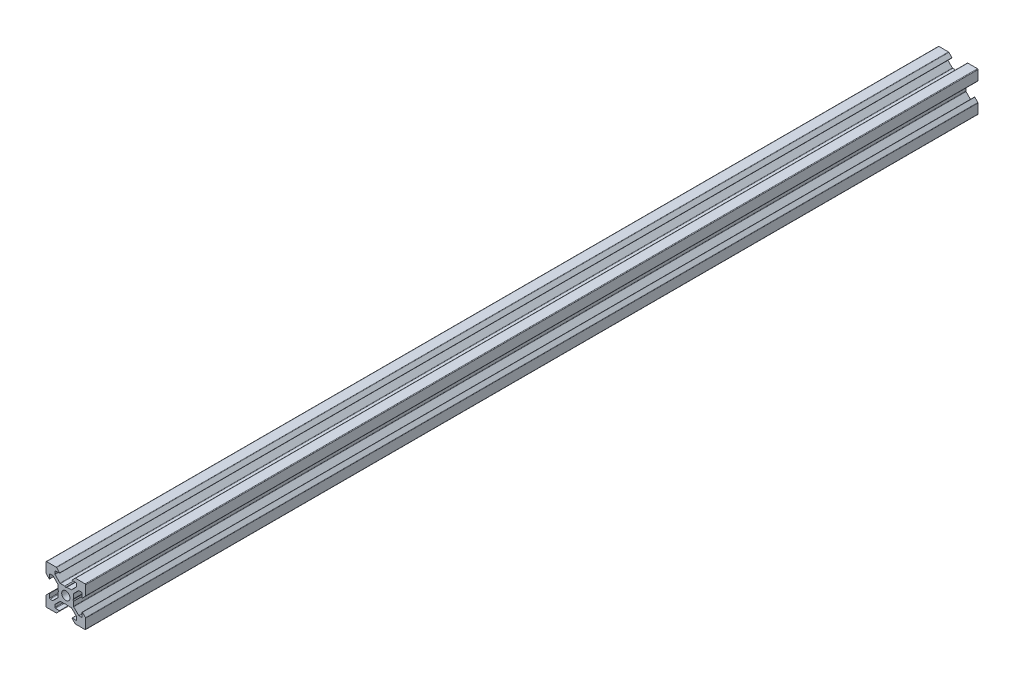
from build123d import *

# Parameters (mm, degrees)
BOSS_EXTRU_1_DEPTH = 450


with BuildPart() as part:
    # Esquisse1 → Boss.-Extru.1 (new body)
    with BuildSketch(Plane.XY):
        with BuildLine():
            Line((18.774857412, -2.895228684), (18.774857412, -4.894568513))
            ThreePointArc((18.774857412, -4.894568513), (18.686989447, -5.106700547), (18.474857412, -5.194568513))
            Line((18.474857412, -5.194568513), (17.259121481, -5.194568513))
            ThreePointArc((17.259121481, -5.194568513), (17.144316451, -5.171732372), (17.046989447, -5.106700547))
            Line((17.046989447, -5.106700547), (14.56338555, -2.62309665))
            ThreePointArc((14.56338555, -2.62309665), (14.498353724, -2.525769645), (14.475517584, -2.410964616))
            Line((14.475517584, -2.410964616), (14.475517584, -0.214843927))
            Line((14.475517584, -0.214843927), (14.175517584, 0.304771316))
            Line((14.175517584, 0.304771316), (14.475517584, 0.824386558))
            Line((14.475517584, 0.824386558), (14.475517584, 3.020507247))
            ThreePointArc((14.475517584, 3.020507247), (14.498353724, 3.135312277), (14.56338555, 3.232639281))
            Line((14.56338555, 3.232639281), (17.046989447, 5.716243178))
            ThreePointArc((17.046989447, 5.716243178), (17.144316451, 5.781275004), (17.259121481, 5.804111144))
            Line((17.259121481, 5.804111144), (18.474857412, 5.804111144))
            ThreePointArc((18.474857412, 5.804111144), (18.686989447, 5.716243178), (18.774857412, 5.504111144))
            Line((18.774857412, 5.504111144), (18.774857412, 3.504771316))
            ThreePointArc((18.774857412, 3.504771316), (18.836589069, 3.412383362), (18.94556809, 3.434060638))
            Line((18.94556809, 3.434060638), (20.486989447, 4.975481994))
            ThreePointArc((20.486989447, 4.975481994), (20.552021272, 5.072808998), (20.574857412, 5.187614028))
            Line((20.574857412, 5.187614028), (20.574857412, 10.004771316))
            ThreePointArc((20.574857412, 10.004771316), (20.486989447, 10.21690335), (20.274857412, 10.304771316))
            Line((20.274857412, 10.304771316), (15.457700125, 10.304771316))
            ThreePointArc((15.457700125, 10.304771316), (15.342895095, 10.281935175), (15.24556809, 10.21690335))
            Line((15.24556809, 10.21690335), (13.704146734, 8.675481994))
            ThreePointArc((13.704146734, 8.675481994), (13.682469459, 8.566502972), (13.774857412, 8.504771316))
            Line((13.774857412, 8.504771316), (15.77419724, 8.504771316))
            ThreePointArc((15.77419724, 8.504771316), (15.986329275, 8.41690335), (16.07419724, 8.204771316))
            Line((16.07419724, 8.204771316), (16.07419724, 6.989035384))
            ThreePointArc((16.07419724, 6.989035384), (16.0513611, 6.874230355), (15.986329275, 6.77690335))
            Line((15.986329275, 6.77690335), (13.502725378, 4.293299453))
            ThreePointArc((13.502725378, 4.293299453), (13.405398373, 4.228267628), (13.290593344, 4.205431487))
            Line((13.290593344, 4.205431487), (11.094472654, 4.205431487))
            Line((11.094472654, 4.205431487), (10.574857412, 3.905431487))
            Line((10.574857412, 3.905431487), (10.05524217, 4.205431487))
            Line((10.05524217, 4.205431487), (7.859121481, 4.205431487))
            ThreePointArc((7.859121481, 4.205431487), (7.744316451, 4.228267628), (7.646989447, 4.293299453))
            Line((7.646989447, 4.293299453), (5.16338555, 6.77690335))
            ThreePointArc((5.16338555, 6.77690335), (5.098353724, 6.874230355), (5.075517584, 6.989035384))
            Line((5.075517584, 6.989035384), (5.075517584, 8.204771316))
            ThreePointArc((5.075517584, 8.204771316), (5.16338555, 8.41690335), (5.375517584, 8.504771316))
            Line((5.375517584, 8.504771316), (7.374857412, 8.504771316))
            ThreePointArc((7.374857412, 8.504771316), (7.467245365, 8.566502972), (7.44556809, 8.675481994))
            Line((7.44556809, 8.675481994), (5.904146734, 10.21690335))
            ThreePointArc((5.904146734, 10.21690335), (5.806819729, 10.281935175), (5.6920147, 10.304771316))
            Line((5.6920147, 10.304771316), (0.874857412, 10.304771316))
            ThreePointArc((0.874857412, 10.304771316), (0.662725378, 10.21690335), (0.574857412, 10.004771316))
            Line((0.574857412, 10.004771316), (0.574857412, 5.187614028))
            ThreePointArc((0.574857412, 5.187614028), (0.597693552, 5.072808998), (0.662725378, 4.975481994))
            Line((0.662725378, 4.975481994), (2.204146734, 3.434060638))
            ThreePointArc((2.204146734, 3.434060638), (2.313125755, 3.412383362), (2.374857412, 3.504771316))
            Line((2.374857412, 3.504771316), (2.374857412, 5.504111144))
            ThreePointArc((2.374857412, 5.504111144), (2.462725378, 5.716243178), (2.674857412, 5.804111144))
            Line((2.674857412, 5.804111144), (3.890593344, 5.804111144))
            ThreePointArc((3.890593344, 5.804111144), (4.005398373, 5.781275004), (4.102725378, 5.716243178))
            Line((4.102725378, 5.716243178), (6.586329275, 3.232639281))
            ThreePointArc((6.586329275, 3.232639281), (6.6513611, 3.135312277), (6.67419724, 3.020507247))
            Line((6.67419724, 3.020507247), (6.67419724, 0.824386558))
            Line((6.67419724, 0.824386558), (6.97419724, 0.304771316))
            Line((6.97419724, 0.304771316), (6.67419724, -0.214843927))
            Line((6.67419724, -0.214843927), (6.67419724, -2.410964616))
            ThreePointArc((6.67419724, -2.410964616), (6.6513611, -2.525769645), (6.586329275, -2.62309665))
            Line((6.586329275, -2.62309665), (4.102725378, -5.106700547))
            ThreePointArc((4.102725378, -5.106700547), (4.005398373, -5.171732372), (3.890593344, -5.194568513))
            Line((3.890593344, -5.194568513), (2.674857412, -5.194568513))
            ThreePointArc((2.674857412, -5.194568513), (2.462725378, -5.106700547), (2.374857412, -4.894568513))
            Line((2.374857412, -4.894568513), (2.374857412, -2.895228684))
            ThreePointArc((2.374857412, -2.895228684), (2.313125755, -2.802840731), (2.204146734, -2.824518006))
            Line((2.204146734, -2.824518006), (0.662725378, -4.365939362))
            ThreePointArc((0.662725378, -4.365939362), (0.597693552, -4.463266367), (0.574857412, -4.578071397))
            Line((0.574857412, -4.578071397), (0.574857412, -9.395228684))
            ThreePointArc((0.574857412, -9.395228684), (0.662725378, -9.607360719), (0.874857412, -9.695228684))
            Line((0.874857412, -9.695228684), (5.6920147, -9.695228684))
            ThreePointArc((5.6920147, -9.695228684), (5.806819729, -9.672392544), (5.904146734, -9.607360719))
            Line((5.904146734, -9.607360719), (7.44556809, -8.065939362))
            ThreePointArc((7.44556809, -8.065939362), (7.467245365, -7.956960341), (7.374857412, -7.895228684))
            Line((7.374857412, -7.895228684), (5.375517584, -7.895228684))
            ThreePointArc((5.375517584, -7.895228684), (5.16338555, -7.807360719), (5.075517584, -7.595228684))
            Line((5.075517584, -7.595228684), (5.075517584, -6.379492753))
            ThreePointArc((5.075517584, -6.379492753), (5.098353724, -6.264687723), (5.16338555, -6.167360719))
            Line((5.16338555, -6.167360719), (7.646989447, -3.683756822))
            ThreePointArc((7.646989447, -3.683756822), (7.744316451, -3.618724996), (7.859121481, -3.595888856))
            Line((7.859121481, -3.595888856), (10.05524217, -3.595888856))
            Line((10.05524217, -3.595888856), (10.574857412, -3.295888856))
            Line((10.574857412, -3.295888856), (11.094472654, -3.595888856))
            Line((11.094472654, -3.595888856), (13.290593344, -3.595888856))
            ThreePointArc((13.290593344, -3.595888856), (13.405398373, -3.618724996), (13.502725378, -3.683756822))
            Line((13.502725378, -3.683756822), (15.986329275, -6.167360719))
            ThreePointArc((15.986329275, -6.167360719), (16.0513611, -6.264687723), (16.07419724, -6.379492753))
            Line((16.07419724, -6.379492753), (16.07419724, -7.595228684))
            ThreePointArc((16.07419724, -7.595228684), (15.986329275, -7.807360719), (15.77419724, -7.895228684))
            Line((15.77419724, -7.895228684), (13.774857412, -7.895228684))
            ThreePointArc((13.774857412, -7.895228684), (13.682469459, -7.956960341), (13.704146734, -8.065939362))
            Line((13.704146734, -8.065939362), (15.24556809, -9.607360719))
            ThreePointArc((15.24556809, -9.607360719), (15.342895095, -9.672392544), (15.457700125, -9.695228684))
            Line((15.457700125, -9.695228684), (20.274857412, -9.695228684))
            ThreePointArc((20.274857412, -9.695228684), (20.486989447, -9.607360719), (20.574857412, -9.395228684))
            Line((20.574857412, -9.395228684), (20.574857412, -4.578071397))
            ThreePointArc((20.574857412, -4.578071397), (20.552021272, -4.463266367), (20.486989447, -4.365939362))
            Line((20.486989447, -4.365939362), (18.94556809, -2.824518006))
            ThreePointArc((18.94556809, -2.824518006), (18.836589069, -2.802840731), (18.774857412, -2.895228684))
        make_face()
        with BuildLine():
            ThreePointArc((10.574857412, -1.795228684), (12.059781653, -1.180152925), (12.674857412, 0.304771316))
            ThreePointArc((12.674857412, 0.304771316), (12.059781653, 1.789695556), (10.574857412, 2.404771316))
            ThreePointArc((10.574857412, 2.404771316), (9.089933172, 1.789695556), (8.474857412, 0.304771316))
            ThreePointArc((8.474857412, 0.304771316), (9.089933172, -1.180152925), (10.574857412, -1.795228684))
        make_face(mode=Mode.SUBTRACT)
    extrude(amount=BOSS_EXTRU_1_DEPTH)


solid = part.part
